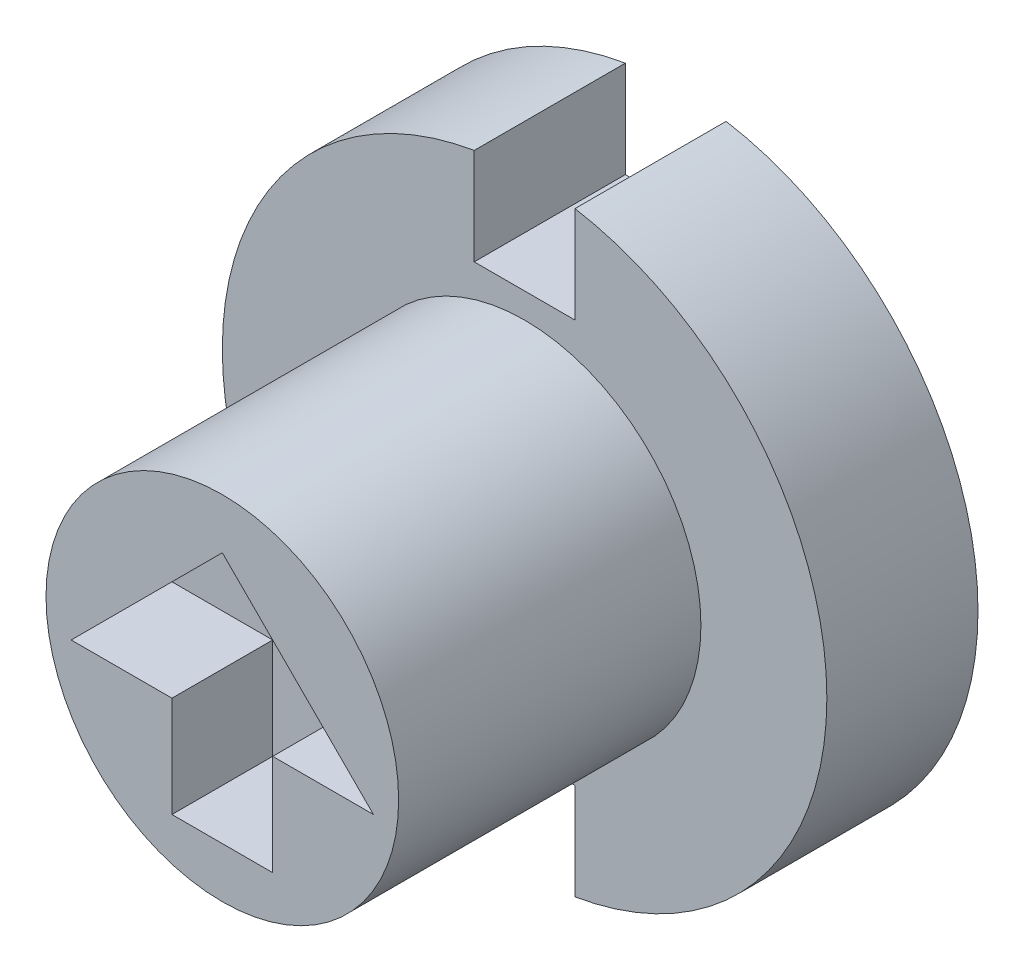
from build123d import *

# Parameters (mm, degrees)
CROQUIS1_R              = 3.5
SALIENTE_EXTRUIR1_DEPTH = 6
CROQUIS2_R              = 6
SALIENTE_EXTRUIR2_DEPTH = 3
CORTAR_EXTRUIR1_DEPTH   = 2
CROQUIS4_W              = 2
CROQUIS4_H              = 2
CORTAR_EXTRUIR2_DEPTH   = 4


with BuildPart() as part:
    # Croquis1 → Saliente-Extruir1 (new body)
    with BuildSketch(Plane.XY):
        with Locations((-4.754102012, 3.97833761)):
            Circle(CROQUIS1_R)
    extrude(amount=SALIENTE_EXTRUIR1_DEPTH)

    # Croquis2 → Saliente-Extruir2 (add)
    with BuildSketch(Plane(origin=(0, 0, 0), x_dir=(-1, 0, 0), z_dir=(0, 0, -1))):
        with Locations((4.754102012, 3.97833761)):
            Circle(CROQUIS2_R)
    extrude(amount=SALIENTE_EXTRUIR2_DEPTH)

    # Croquis3 → Cortar-Extruir1 (cut)
    with BuildSketch(Plane.XY.offset(6)):
        Polygon((-5.754102012, 1.47833761), (-3.754102012, 1.47833761), (-3.754102012, 3.47833761), (-1.754102012, 3.47833761), (-4.754102012, 6.47833761), (-7.754102012, 3.47833761), (-5.754102012, 3.47833761), align=None)
    extrude(amount=-CORTAR_EXTRUIR1_DEPTH, mode=Mode.SUBTRACT)

    # Croquis4 → Cortar-Extruir2 (cut, through all)
    with BuildSketch(Plane.XY):
        with Locations((-4.754102012, 8.97833761)):
            Rectangle(CROQUIS4_W, CROQUIS4_H)
        Polygon((-5.754102012, -0.02166239), (-3.754102012, -0.02166239), (-3.754102012, -2.02166239), (-4.754102012, -2.02166239), (-5.754102012, -2.02166239), align=None)
    extrude(amount=-CORTAR_EXTRUIR2_DEPTH, mode=Mode.SUBTRACT)


solid = part.part
